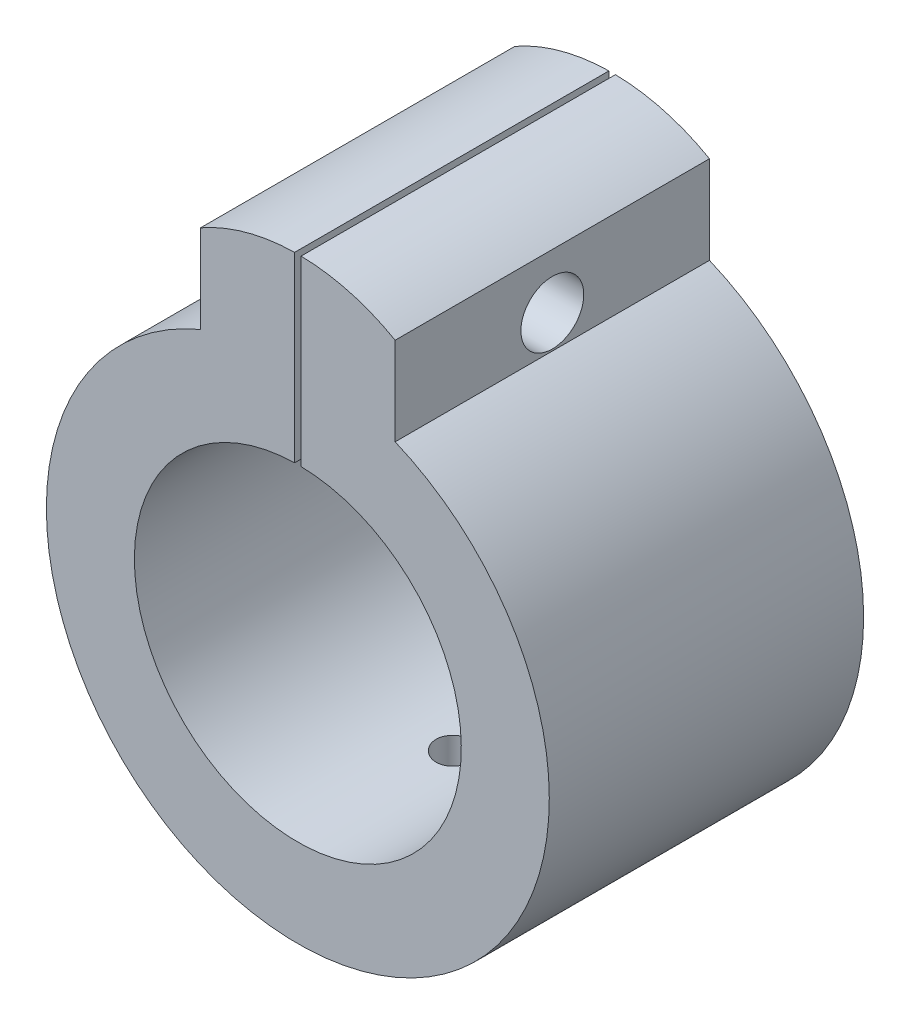
from build123d import *

# Parameters (mm, degrees)
SKETCH_1_R          = 3.5
SKETCH_1_R_2        = 13
EXTRUDE_2_DEPTH     = 10
SKETCH_2_R          = 13
EXTRUDE_3_DEPTH     = 15
SKETCH_3_W          = 0.517195108
SKETCH_3_H          = 18.726193104
CUT_EXTRUDE_1_DEPTH = 26
SKETCH_4_R          = 2.5
CUT_EXTRUDE_2_DEPTH = 43.740275714
CUT_EXTRUDE_3_DEPTH = 11
SKETCH_6_R          = 1.5
CUT_EXTRUDE_4_DEPTH = 21


with BuildPart() as part:
    # 草图1 → 凸台-拉伸2 (new body)
    with BuildSketch(Plane.XY):
        with BuildLine():
            Line((-35, -7), (-7.740275714, -18.44147857))
            ThreePointArc((-7.740275714, -18.44147857), (0, -20), (7.740275714, -18.44147857))
            Line((7.740275714, -18.44147857), (35, -7))
            Line((35, -7), (35, 7))
            Line((35, 7), (7.740275714, 18.44147857))
            Line((7.740275714, 18.44147857), (7.740275714, 25.44147857))
            ThreePointArc((7.740275714, 25.44147857), (0, 27.494244152), (-7.740275714, 25.44147857))
            Line((-7.740275714, 25.44147857), (-7.740275714, 18.44147857))
            Line((-7.740275714, 18.44147857), (-35, 7))
            Line((-35, 7), (-35, -7))
        make_face()
        with Locations((-28, 0)):
            Circle(SKETCH_1_R, mode=Mode.SUBTRACT)
        Circle(SKETCH_1_R_2, mode=Mode.SUBTRACT)
        with Locations((28, 0)):
            Circle(SKETCH_1_R, mode=Mode.SUBTRACT)
    extrude(amount=EXTRUDE_2_DEPTH)

    # 草图2 → 凸台-拉伸3 (add)
    with BuildSketch(Plane.XY.offset(10)):
        with BuildLine():
            Line((-7.740275714, 18.44147857), (-7.740275714, 25.44147857))
            ThreePointArc((-7.740275714, 25.44147857), (0, 27.494244152), (7.740275714, 25.44147857))
            Line((7.740275714, 25.44147857), (7.740275714, 18.44147857))
            ThreePointArc((7.740275714, 18.44147857), (0, -20), (-7.740275714, 18.44147857))
        make_face()
        Circle(SKETCH_2_R, mode=Mode.SUBTRACT)
    extrude(amount=EXTRUDE_3_DEPTH)

    # 草图3 → 切除-拉伸1 (cut, through all)
    with BuildSketch(Plane.XY.offset(25)):
        with Locations((0, 21.741202931)):
            Rectangle(SKETCH_3_W, SKETCH_3_H)
    extrude(amount=-CUT_EXTRUDE_1_DEPTH, mode=Mode.SUBTRACT)

    # 草图4 → 切除-拉伸2 (cut, through all)
    with BuildSketch(Plane(origin=(7.740275714, 0, 0), x_dir=(0, 0, -1), z_dir=(1, 0, 0))):
        with Locations((-12.5, 21.086423576)):
            Circle(SKETCH_4_R)
    extrude(amount=-CUT_EXTRUDE_2_DEPTH, mode=Mode.SUBTRACT)

    # 草图5 → 切除-拉伸3 (cut, through all)
    with BuildSketch(Plane.XY.offset(10)):
        with BuildLine():
            Line((-7.740275714, 18.44147857), (-35, 7))
            Line((-35, 7), (-35, -7))
            Line((-35, -7), (-7.740275714, -18.44147857))
            ThreePointArc((-7.740275714, -18.44147857), (-20, 0), (-7.740275714, 18.44147857))
        make_face()
        with BuildLine():
            Line((7.740275714, 18.44147857), (35, 7))
            Line((35, 7), (35, -7))
            Line((35, -7), (7.740275714, -18.44147857))
            ThreePointArc((7.740275714, -18.44147857), (20, 0), (7.740275714, 18.44147857))
        make_face()
    extrude(amount=-CUT_EXTRUDE_3_DEPTH, mode=Mode.SUBTRACT)

    # 草图6 → 切除-拉伸4 (cut, through all)
    with BuildSketch(Plane(origin=(0, 0, 0), x_dir=(1, 0, 0), z_dir=(0, 1, 0))):
        with Locations((0, -12.5)):
            Circle(SKETCH_6_R)
    extrude(amount=-CUT_EXTRUDE_4_DEPTH, mode=Mode.SUBTRACT)


solid = part.part
